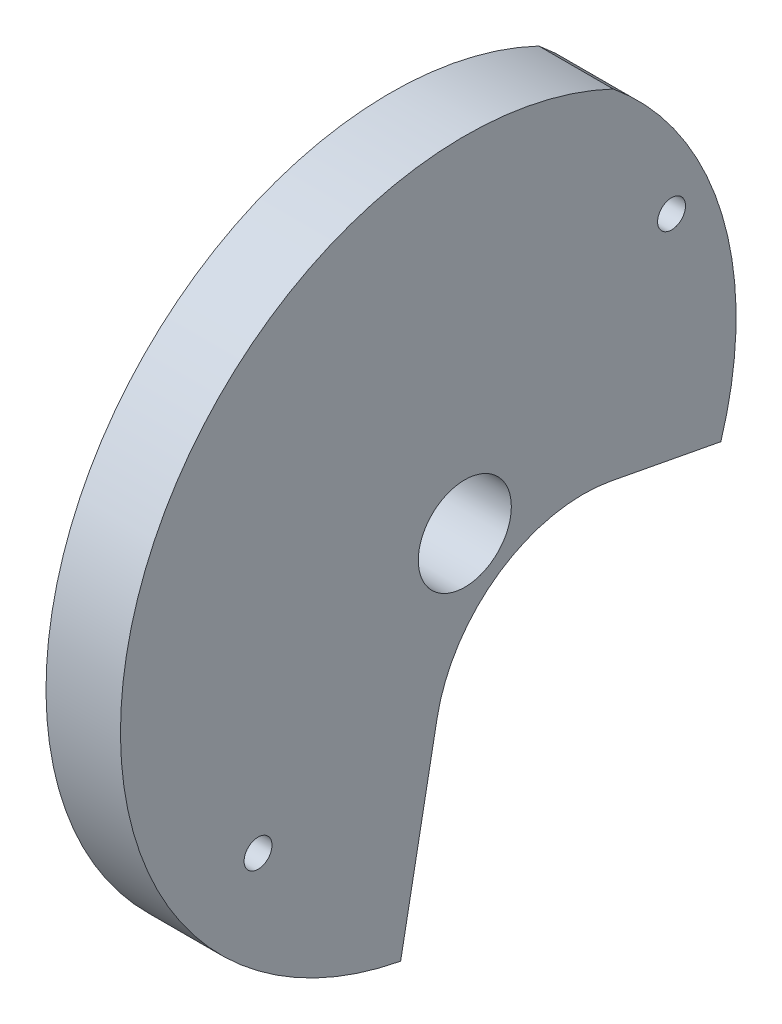
from build123d import *

# Parameters (mm, degrees)
SKETCH_1_R          = 2.5
EXTRUDE_1_DEPTH     = 4
SKETCH_2_R          = 0.75
CUT_EXTRUDE_1_DEPTH = 10
SKETCH_3_R          = 25.464829655
SKETCH_3_R_2        = 18.5
CUT_EXTRUDE_2_DEPTH = 10


with BuildPart() as part:
    # Эскиз1 → Бобышка-Вытянуть1 (new body)
    with BuildSketch(Plane(origin=(0, 0, 0), x_dir=(0, 0, -1), z_dir=(1, 0, 0))):
        with BuildLine():
            Line((7.85991422, -1.49055335), (13.754849795, -2.608468346))
            ThreePointArc((13.754849795, -2.608468346), (13.231778891, 9.584616389), (5.051373997, 18.641431188))
            ThreePointArc((5.051373997, 18.641431188), (-18.822494325, 4.328168593), (-3.59851409, -18.975511385))
            Line((-3.59851409, -18.975511385), (-1.490553351, -7.859914224))
            ThreePointArc((-1.490553351, -7.859914224), (1.865542593, -2.738688528), (7.85991422, -1.49055335))
        make_face()
        Circle(SKETCH_1_R, mode=Mode.SUBTRACT)
    extrude(amount=EXTRUDE_1_DEPTH)

    # Эскиз2 → Вырез-Вытянуть1 (cut)
    with BuildSketch(Plane(origin=(4, 0, 0), x_dir=(0, 0, -1), z_dir=(1, 0, 0))):
        with Locations((-11.107644425, -9.32042034)):
            Circle(SKETCH_2_R)
        with Locations((11.107644425, 9.32042034)):
            Circle(SKETCH_2_R)
    extrude(amount=-CUT_EXTRUDE_1_DEPTH, mode=Mode.SUBTRACT)

    # Эскиз3 → Вырез-Вытянуть2 (cut)
    with BuildSketch(Plane(origin=(4, 0, 0), x_dir=(0, 0, -1), z_dir=(1, 0, 0))):
        Circle(SKETCH_3_R)
        Circle(SKETCH_3_R_2, mode=Mode.SUBTRACT)
    extrude(amount=-CUT_EXTRUDE_2_DEPTH, mode=Mode.SUBTRACT)


solid = part.part
